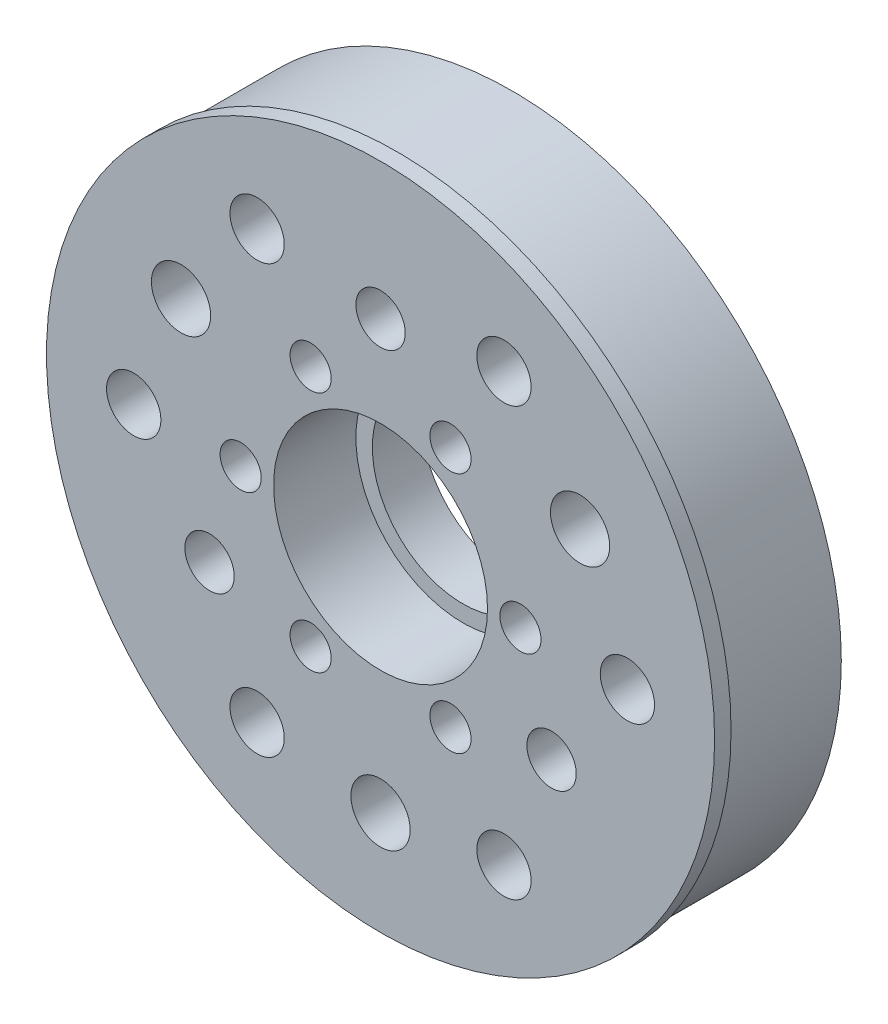
from build123d import *

# Parameters (mm, degrees)
SKETCH_1_R                   = 20
EXTRUDE_1_DEPTH              = 7
SKETCH_2_R                   = 20.3
EXTRUDE_2_DEPTH              = 1
SKETCH_3_R                   = 6.5
CUT_EXTRUDE_1_DEPTH          = 5
SKETCH_4_R                   = 5.5
CUT_EXTRUDE_2_DEPTH          = 4
CUT_EXTRUDE_START            = -9
SKETCH_5_R                   = 1.5
CUT_EXTRUDE_3_DEPTH          = 10
PATTERN_CIRCULAR_1_COUNT     = 3
HOLE_WIZARD_M3_1_D           = 3.6
HOLE_WIZARD_M3_1_CSINK_D     = 6.3
HOLE_WIZARD_M3_1_CSINK_ANGLE = 90
PATTERN_CIRCULAR_2_COUNT     = 3
M4X0_7_1_D                   = 3.3
M3X0_5_1_D                   = 2.5
PATTERN_CIRCULAR_3_COUNT     = 6


with BuildPart() as part:
    # ｽｹｯﾁ1 → ﾎﾞｽ - 押し出し1 (new body)
    with BuildSketch(Plane.XY):
        Circle(SKETCH_1_R)
    extrude(amount=EXTRUDE_1_DEPTH)

    # ｽｹｯﾁ2 → ﾎﾞｽ - 押し出し2 (add)
    with BuildSketch(Plane.XY.offset(7)):
        Circle(SKETCH_2_R)
    extrude(amount=EXTRUDE_2_DEPTH)

    # ｽｹｯﾁ3 → ｶｯﾄ - 押し出し1 (cut)
    with BuildSketch(Plane.XY.offset(8)):
        Circle(SKETCH_3_R)
    extrude(amount=-CUT_EXTRUDE_1_DEPTH, mode=Mode.SUBTRACT)

    # ｽｹｯﾁ4 → ｶｯﾄ - 押し出し2 (cut, through all)
    with BuildSketch(Plane.XY.offset(3)):
        Circle(SKETCH_4_R)
    extrude(amount=-CUT_EXTRUDE_2_DEPTH, mode=Mode.SUBTRACT)

    # ｽｹｯﾁ5 → ｶｯﾄ - 押し出し3 (cut)
    with BuildSketch(Plane.XY.offset(8).offset(CUT_EXTRUDE_START)):
        with Locations((0, 12)):
            Circle(SKETCH_5_R)
    cut_extrude_3 = extrude(amount=CUT_EXTRUDE_3_DEPTH, mode=Mode.SUBTRACT)

    # 円形ﾊﾟﾀｰﾝ1: ｶｯﾄ - 押し出し3 ×3 about axis
    pattern_circular_1_axis = Axis((0, 0, 0), (0, 0, 1))
    for i in range(1, PATTERN_CIRCULAR_1_COUNT):
        add(cut_extrude_3.rotate(pattern_circular_1_axis, i * 360 / PATTERN_CIRCULAR_1_COUNT), mode=Mode.SUBTRACT)

    # M3 平皿頭ねじ用皿穴1 (through all)
    with Locations(Plane(origin=(0, 0, 0), x_dir=(-1, 0, 0), z_dir=(0, 0, -1))):
        with Locations((0, -14)):
            hole_wizard_m3_1 = CounterSinkHole(HOLE_WIZARD_M3_1_D / 2, HOLE_WIZARD_M3_1_CSINK_D / 2, counter_sink_angle=HOLE_WIZARD_M3_1_CSINK_ANGLE)

    # 円形ﾊﾟﾀｰﾝ2: M3 平皿頭ねじ用皿穴1 ×3 about axis
    pattern_circular_2_axis = Axis((0, 0, 0), (0, 0, 1))
    for i in range(1, PATTERN_CIRCULAR_2_COUNT):
        add(hole_wizard_m3_1.rotate(pattern_circular_2_axis, i * 360 / PATTERN_CIRCULAR_2_COUNT), mode=Mode.SUBTRACT)

    # M4x0.7 ねじ穴1 (through all)
    with Locations(Plane(origin=(0, 0, 0), x_dir=(-1, 0, 0), z_dir=(0, 0, -1))):
        with Locations((15, 0)):
            m4x0_7_1 = Hole(M4X0_7_1_D / 2)

    # M3x0.5 ねじ穴1 (through all)
    with Locations(Plane(origin=(0, 0, 0), x_dir=(-1, 0, 0), z_dir=(0, 0, -1))):
        with Locations((8.5, 0)):
            m3x0_5_1 = Hole(M3X0_5_1_D / 2)

    # 円形ﾊﾟﾀｰﾝ3: M4x0.7 ねじ穴1, M3x0.5 ねじ穴1 ×6 about axis
    pattern_circular_3_axis = Axis((0, 0, 0), (0, 0, 1))
    for i in range(1, PATTERN_CIRCULAR_3_COUNT):
        add(m4x0_7_1.rotate(pattern_circular_3_axis, i * 360 / PATTERN_CIRCULAR_3_COUNT), mode=Mode.SUBTRACT)
        add(m3x0_5_1.rotate(pattern_circular_3_axis, i * 360 / PATTERN_CIRCULAR_3_COUNT), mode=Mode.SUBTRACT)


solid = part.part
